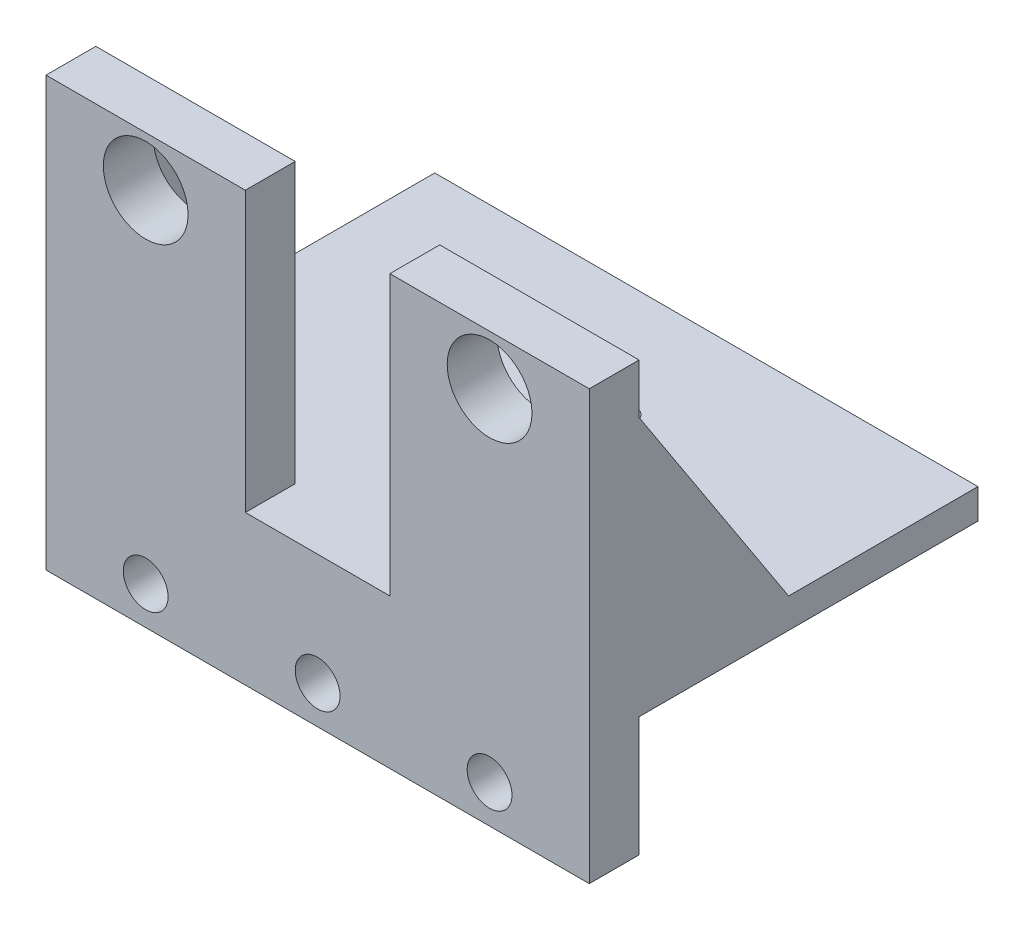
from build123d import *

# Parameters (mm, degrees)
SKETCH1_W                 = 54.5
SKETCH1_H                 = 39
BOSS_EXTRUDE1_DEPTH       = 3
SKETCH10_R                = 7
CUT_EXTRUDE1_DEPTH        = 5
M2_CLEARANCE_HOLE1_D      = 2.4
M2_CLEARANCE_HOLE1_DEPTH  = 17
M2_CLEARANCE_HOLE1_TIP    = 0.721032743
SKETCH12_W                = 20
SKETCH12_H                = 5
BOSS_EXTRUDE2_DEPTH       = 28
SKETCH13_R                = 4.25
CUT_EXTRUDE2_DEPTH        = 5
SKETCH16_W                = 54.5
SKETCH16_H                = 5
BOSS_EXTRUDE4_DEPTH       = 12
F_8_CLEARANCE_HOLE1_D     = 4.4958
F_8_CLEARANCE_HOLE1_DEPTH = 17
F_8_CLEARANCE_HOLE1_TIP   = 1.350674586
RIB2_REACH                = 70.517
SKETCH20_WALL_W           = 166.493784704
SKETCH20_WALL_H           = 5
RIB4_REACH                = 70.517
SKETCH21_WALL_W           = 166.493784704
SKETCH21_WALL_H           = 5


with BuildPart() as part:
    # Sketch1 → Boss-Extrude1 (new body)
    with BuildSketch(Plane(origin=(0, 0, 0), x_dir=(1, 0, 0), z_dir=(0, 1, 0))):
        with Locations((-13.399543841, 8.129312584)):
            Rectangle(SKETCH1_W, SKETCH1_H)
    extrude(amount=BOSS_EXTRUDE1_DEPTH)

    # Sketch10 → Cut-Extrude1 (cut)
    with BuildSketch(Plane(origin=(0, 3, 0), x_dir=(1, 0, 0), z_dir=(0, 1, 0))):
        with Locations(Location((-10.149543841, 8.129312584, 0), (0, 0, 270))):
            Circle(SKETCH10_R)
    extrude(amount=-CUT_EXTRUDE1_DEPTH, mode=Mode.SUBTRACT)

    # M2 Clearance Hole1
    with Locations(Plane(origin=(-10.149543841, 3, -0.129312584), x_dir=(0, 0, 1), z_dir=(0, 1, 0))):
        with Locations((0, 0), (-8, 7.99475453), (-8, -7.99475453), (-16, 0)):
            Hole(M2_CLEARANCE_HOLE1_D / 2, depth=M2_CLEARANCE_HOLE1_DEPTH)
            with Locations((0, 0, -(M2_CLEARANCE_HOLE1_DEPTH + M2_CLEARANCE_HOLE1_TIP / 2))):  # 118° drill point
                Cone(0, M2_CLEARANCE_HOLE1_D / 2, M2_CLEARANCE_HOLE1_TIP, mode=Mode.SUBTRACT)

    # Sketch12 → Boss-Extrude2 (add)
    with BuildSketch(Plane(origin=(0, 3, 0), x_dir=(1, 0, 0), z_dir=(0, 1, 0))):
        with Locations((3.850456159, -8.870687416)):
            Rectangle(SKETCH12_W, SKETCH12_H)
        with Locations((-30.649543841, -8.870687416)):
            Rectangle(SKETCH12_W, SKETCH12_H)
    extrude(amount=BOSS_EXTRUDE2_DEPTH)

    # Sketch13 → Cut-Extrude2 (cut)
    with BuildSketch(Plane(origin=(0, 0, 6.370687416), x_dir=(-1, 0, 0), z_dir=(0, 0, -1))):
        with Locations((-3.850456159, 26)):
            Circle(SKETCH13_R)
        with Locations((30.649543841, 26)):
            Circle(SKETCH13_R)
    extrude(amount=-CUT_EXTRUDE2_DEPTH, mode=Mode.SUBTRACT)

    # Sketch16 → Boss-Extrude4 (add)
    with BuildSketch(Plane.XZ):
        with Locations((-13.399543841, 8.870687416)):
            Rectangle(SKETCH16_W, SKETCH16_H)
    extrude(amount=BOSS_EXTRUDE4_DEPTH)

    # #8 Clearance Hole1
    with Locations(Plane(origin=(-30.649543841, -8.2, 11.370687416), x_dir=(1, 0, 0), z_dir=(0, 0, 1))):
        with Locations((0, 0), (17.25, 0), (34.5, 0)):
            Hole(F_8_CLEARANCE_HOLE1_D / 2, depth=F_8_CLEARANCE_HOLE1_DEPTH)
            with Locations((0, 0, -(F_8_CLEARANCE_HOLE1_DEPTH + F_8_CLEARANCE_HOLE1_TIP / 2))):  # 118° drill point
                Cone(0, F_8_CLEARANCE_HOLE1_D / 2, F_8_CLEARANCE_HOLE1_TIP, mode=Mode.SUBTRACT)

    # Sketch20 wall → Rib2 (add, up to next)
    with BuildSketch(Plane(origin=(13.850456159, 14.5, -1.129312584), x_dir=(0, -0.837610596839, -0.546267780547), z_dir=(0, 0.546267780547, -0.837610596839)), mode=Mode.PRIVATE) as rib2_sk1:
        with Locations((0, 2.5)):
            Rectangle(SKETCH20_WALL_W, SKETCH20_WALL_H)
    rib2_tool1 = extrude(rib2_sk1.sketch, amount=-RIB2_REACH, mode=Mode.PRIVATE) - part.part
    add(rib2_tool1.solids().sort_by_distance((13.850456159, 14.5, -1.129312584))[0])

    # Sketch21 wall → Rib4 (add, up to next)
    with BuildSketch(Plane(origin=(-40.649543841, 14.5, -1.129312584), x_dir=(0, -0.837610596839, -0.546267780547), z_dir=(0, -0.546267780547, 0.837610596839)), mode=Mode.PRIVATE) as rib4_sk1:
        with Locations((0, 2.5)):
            Rectangle(SKETCH21_WALL_W, SKETCH21_WALL_H)
    rib4_tool1 = extrude(rib4_sk1.sketch, amount=RIB4_REACH, mode=Mode.PRIVATE) - part.part
    add(rib4_tool1.solids().sort_by_distance((-40.649543841, 14.5, -1.129312584))[0])


solid = part.part
